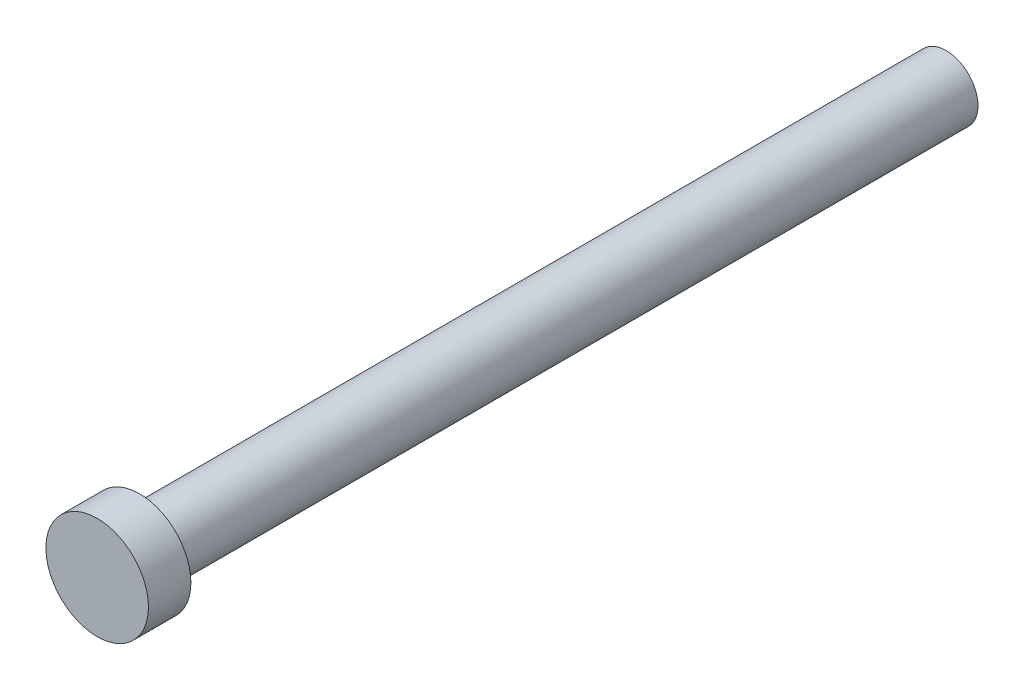
from build123d import *

# Parameters (mm, degrees)
SKETCH1_R           = 1.5
BOSS_EXTRUDE1_DEPTH = 40
SKETCH2_R           = 2.415394365
SKETCH2_R_2         = 1.5
BOSS_EXTRUDE2_DEPTH = 2


with BuildPart() as part:
    # Sketch1 → Boss-Extrude1 (new body)
    with BuildSketch(Plane.XY):
        Circle(SKETCH1_R)
    extrude(amount=BOSS_EXTRUDE1_DEPTH)

    # Sketch2 → Boss-Extrude2 (add)
    with BuildSketch(Plane.XY.offset(40)):
        Circle(SKETCH2_R)
        Circle(SKETCH2_R_2, mode=Mode.SUBTRACT)
    extrude(amount=-BOSS_EXTRUDE2_DEPTH)


solid = part.part
